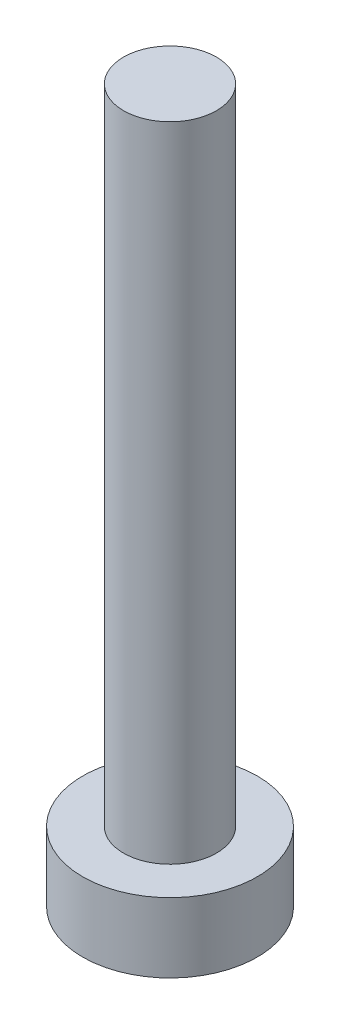
from build123d import *

# Parameters (mm, degrees)
SKETCH1_R           = 1.335
BOSS_EXTRUDE1_DEPTH = 18.48
SKETCH2_R           = 2.51
BOSS_EXTRUDE2_DEPTH = 2


with BuildPart() as part:
    # Sketch1 → Boss-Extrude1 (new body)
    with BuildSketch(Plane(origin=(0, 0, 0), x_dir=(1, 0, 0), z_dir=(0, 1, 0))):
        Circle(SKETCH1_R)
    extrude(amount=BOSS_EXTRUDE1_DEPTH)

    # Sketch2 → Boss-Extrude2 (add)
    with BuildSketch(Plane.XZ):
        Circle(SKETCH2_R)
    extrude(amount=BOSS_EXTRUDE2_DEPTH)


solid = part.part
